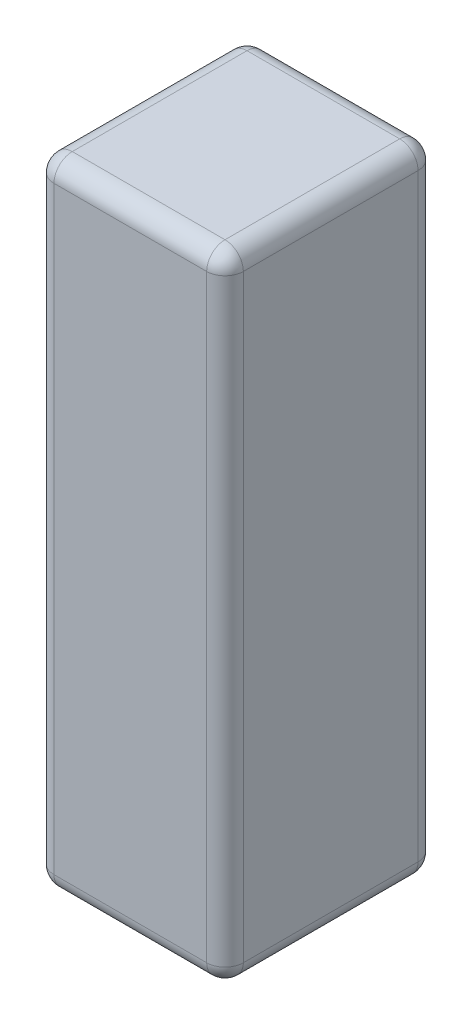
from build123d import *

# Parameters (mm, degrees)
SKETCH1_W           = 31
SKETCH1_H           = 34.6
BOSS_EXTRUDE1_DEPTH = 104
FILLET1_R           = 3


with BuildPart() as part:
    # Sketch1 → Boss-Extrude1 (new body)
    with BuildSketch(Plane(origin=(0, 0, 0), x_dir=(1, 0, 0), z_dir=(0, 1, 0))):
        with Locations((15.5, 17.3)):
            Rectangle(SKETCH1_W, SKETCH1_H)
    extrude(amount=BOSS_EXTRUDE1_DEPTH)

    # Fillet1
    fillet1_edges = [part.edges().sort_by_distance(p)[0] for p in [
        (31, 104, -17.3),
        (15.5, 104, -34.6),
        (0, 104, -17.3),
        (15.5, 0, -34.6),
        (31, 0, -17.3),
        (15.5, 0, 0),
        (0, 0, -17.3),
        (15.5, 104, 0),
        (0, 52, -34.6),
        (31, 52, -34.6),
        (31, 52, 0),
        (0, 52, 0),
    ]]
    fillet(fillet1_edges, radius=FILLET1_R)


solid = part.part
